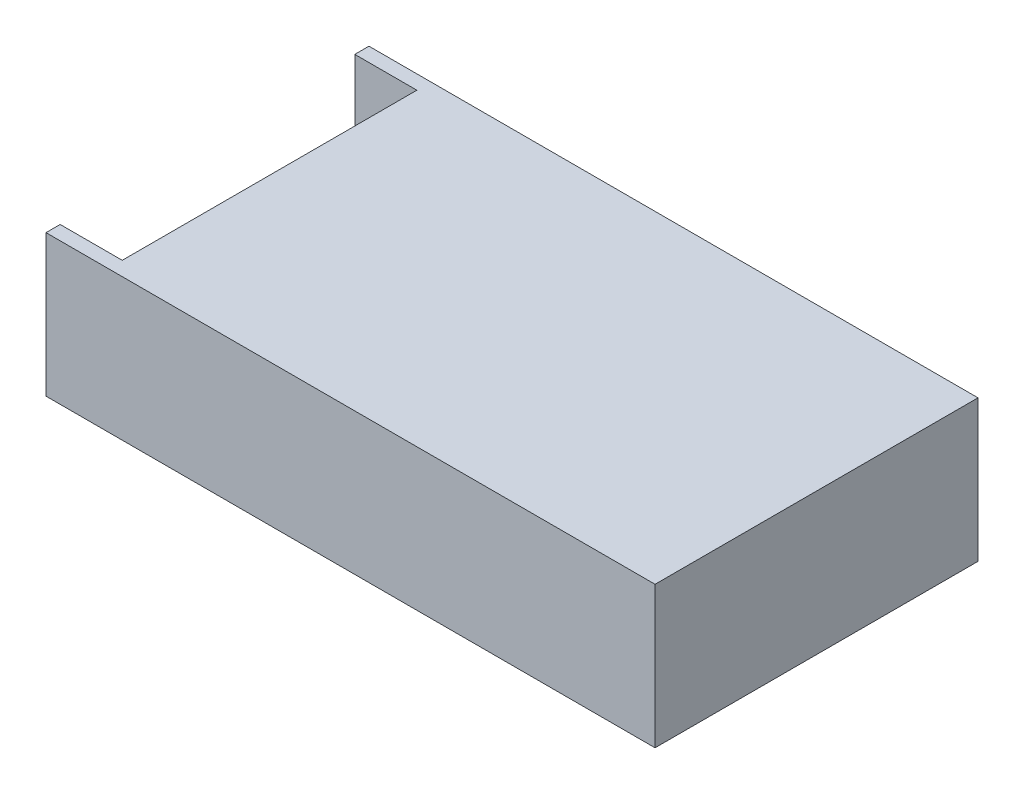
from build123d import *

# Parameters (mm, degrees)
ESBO_O1_W                = 215
ESBO_O1_H                = 114
RESSALTO_EXTRUS_O1_DEPTH = 50
CORTE_EXTRUS_O1_START    = -5
CORTE_EXTRUS_O1_DEPTH    = 104
ESBO_O4_R                = 2
CORTE_EXTRUS_O2_DEPTH    = 10


with BuildPart() as part:
    # Esboço1 → Ressalto-extrusão1 (new body)
    with BuildSketch(Plane(origin=(0, 0, 0), x_dir=(1, 0, 0), z_dir=(0, 1, 0))):
        Rectangle(ESBO_O1_W, ESBO_O1_H)
    extrude(amount=RESSALTO_EXTRUS_O1_DEPTH)

    # Esboço3 → Corte-extrusão1 (cut)
    with BuildSketch(Plane.XY.offset(57).offset(CORTE_EXTRUS_O1_START)):
        Polygon((-107.5, 50), (-85.58523496, 50), (-85.58523496, 16.13389081), (-102.483117777, 16.13389081), (-102.483117777, 6.426889092), (-107.5, 6.426889092), (-107.5, 17.457061978), align=None)
    extrude(amount=-CORTE_EXTRUS_O1_DEPTH, mode=Mode.SUBTRACT)

    # Esboço4 → Corte-extrusão2 (cut)
    with BuildSketch(Plane.XZ):
        with Locations((96, 42)):
            Circle(ESBO_O4_R)
        with Locations((-29.6, 42)):
            Circle(ESBO_O4_R)
        with Locations((-29.6, -43)):
            Circle(ESBO_O4_R)
        with Locations((96, -43)):
            Circle(ESBO_O4_R)
    extrude(amount=-CORTE_EXTRUS_O2_DEPTH, mode=Mode.SUBTRACT)


solid = part.part
